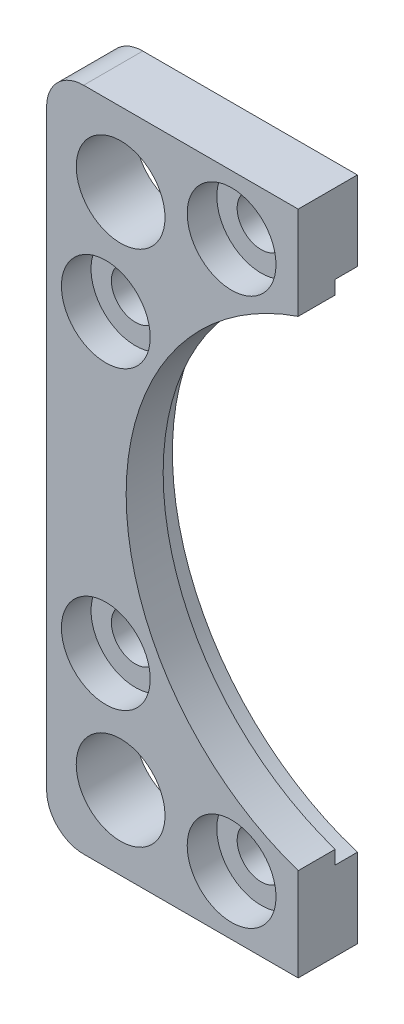
from build123d import *

# Parameters (mm, degrees)
SKETCH1_R           = 6
SKETCH1_R_2         = 3.25
BOSS_EXTRUDE1_DEPTH = 4
SKETCH2_R           = 36
CUT_EXTRUDE1_DEPTH  = 3
FILLET1_R           = 5
SKETCH3_R           = 6
CUT_EXTRUDE2_DEPTH  = 4


with BuildPart() as part:
    # Sketch1 → Boss-Extrude1 (new body, symmetric)
    with BuildSketch(Plane.XY):
        with BuildLine():
            Line((-11, 45), (-11, 32.435512945))
            ThreePointArc((-11, 32.435512945), (-34.25, 0), (-11, -32.435512945))
            Line((-11, -32.435512945), (-11, -45))
            Line((-11, -45), (-45, -45))
            Line((-45, -45), (-45, 45))
            Line((-45, 45), (-11, 45))
        make_face()
        with Locations((-35, 35)):
            Circle(SKETCH1_R, mode=Mode.SUBTRACT)
        with Locations((-35, -35)):
            Circle(SKETCH1_R, mode=Mode.SUBTRACT)
        with Locations((-37, 20)):
            Circle(SKETCH1_R_2, mode=Mode.SUBTRACT)
        with Locations((-37, -20)):
            Circle(SKETCH1_R_2, mode=Mode.SUBTRACT)
        with Locations((-20, 37)):
            Circle(SKETCH1_R_2, mode=Mode.SUBTRACT)
        with Locations((-20, -37)):
            Circle(SKETCH1_R_2, mode=Mode.SUBTRACT)
    extrude(amount=BOSS_EXTRUDE1_DEPTH, both=True)

    # Sketch2 → Cut-Extrude1 (cut)
    with BuildSketch(Plane(origin=(0, 0, -4), x_dir=(-1, 0, 0), z_dir=(0, 0, -1))):
        Circle(SKETCH2_R)
    extrude(amount=-CUT_EXTRUDE1_DEPTH, mode=Mode.SUBTRACT)

    # Fillet1
    fillet1_edges = [part.edges().sort_by_distance(p)[0] for p in [
        (-45, -45, 0),
        (-45, 45, 0),
    ]]
    fillet(fillet1_edges, radius=FILLET1_R)

    # Sketch3 → Cut-Extrude2 (cut)
    with BuildSketch(Plane.XY.offset(4)):
        with Locations((-20, 37)):
            Circle(SKETCH3_R)
        with Locations((-37, 20)):
            Circle(SKETCH3_R)
        with Locations((-37, -20)):
            Circle(SKETCH3_R)
        with Locations((-20, -37)):
            Circle(SKETCH3_R)
    extrude(amount=-CUT_EXTRUDE2_DEPTH, mode=Mode.SUBTRACT)


solid = part.part
